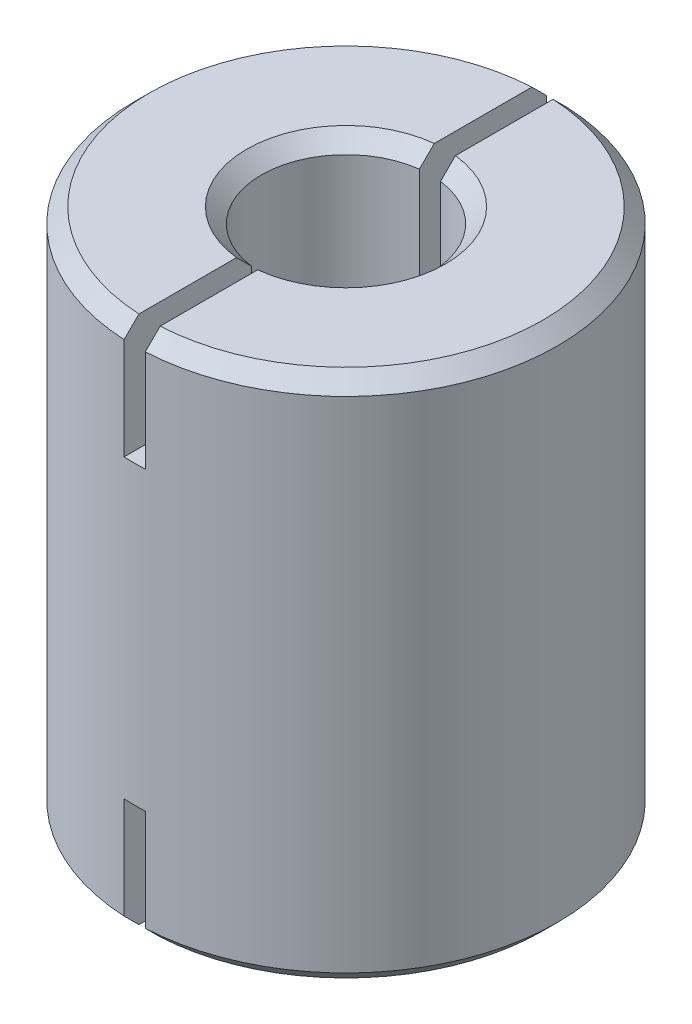
from build123d import *

# Parameters (mm, degrees)
SKETCH1_R               = 10
SKETCH1_R_2             = 4
BOSS_EXTRUDE1_DEPTH     = 12.5
CHAMFER1_SIZE           = 0.7
SKETCH2_W               = 1
SKETCH2_H               = 20.36289329
CUT_EXTRUDE1_DEPTH      = 40
CUT_EXTRUDE1_DEPTH_BACK = 36


with BuildPart() as part:
    # Sketch1 → Boss-Extrude1 (new body, symmetric)
    with BuildSketch(Plane(origin=(0, 0, 0), x_dir=(1, 0, 0), z_dir=(0, 1, 0))):
        Circle(SKETCH1_R)
        Circle(SKETCH1_R_2, mode=Mode.SUBTRACT)
    extrude(amount=BOSS_EXTRUDE1_DEPTH, both=True)

    # Chamfer1
    chamfer1_edges = [part.edges().sort_by_distance(p)[0] for p in [
        (-10, -12.5, 0),
        (-10, 12.5, 0),
        (-4, -12.5, 0),
        (-4, 12.5, 0),
    ]]
    chamfer(chamfer1_edges, length=CHAMFER1_SIZE)

    # Sketch2 → Cut-Extrude1 (cut, two sides)
    with BuildSketch(Plane.XY) as cut_extrude1_sk:
        with Locations((0, 17.181446645)):
            Rectangle(SKETCH2_W, SKETCH2_H)
        with Locations((0, -17.181446645)):
            Rectangle(SKETCH2_W, SKETCH2_H)
    extrude(amount=CUT_EXTRUDE1_DEPTH, mode=Mode.SUBTRACT)
    extrude(cut_extrude1_sk.sketch, amount=-CUT_EXTRUDE1_DEPTH_BACK, mode=Mode.SUBTRACT)


solid = part.part
